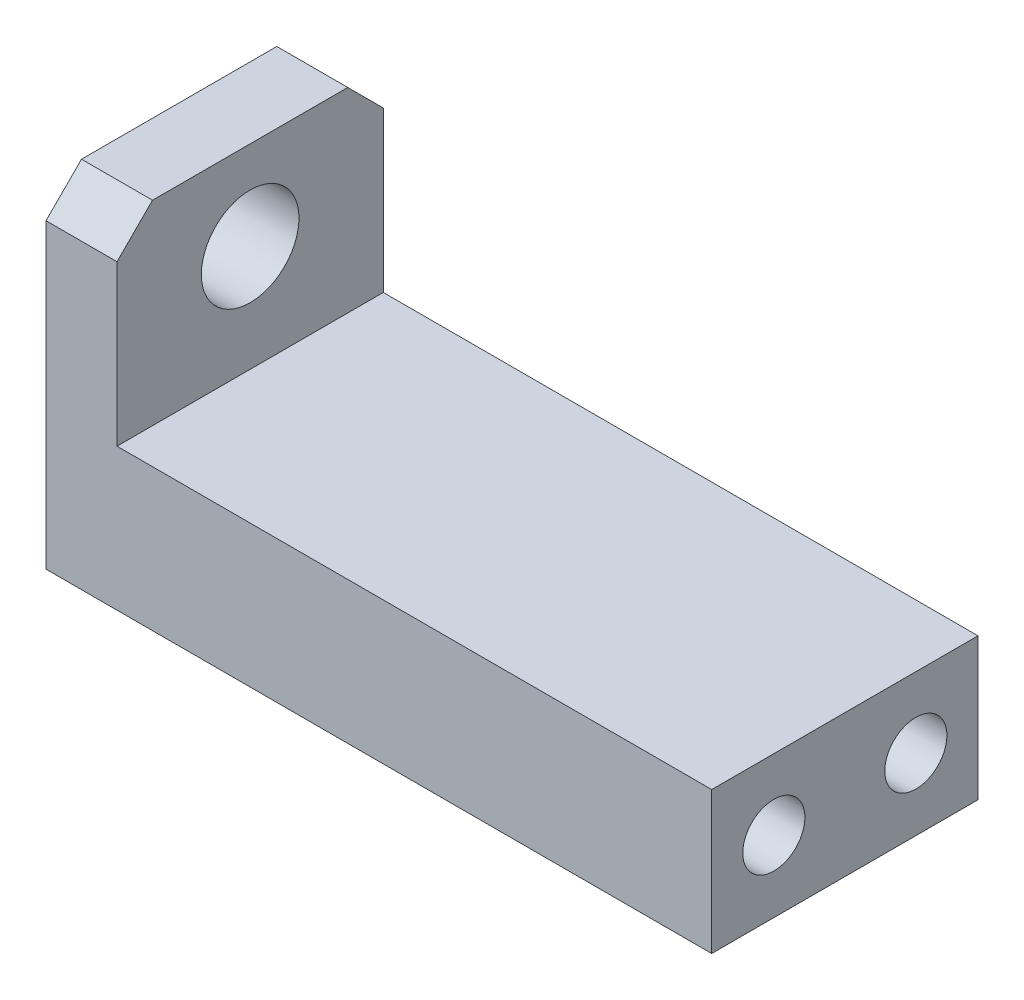
from build123d import *

# Parameters (mm, degrees)
BOSS_EXTRUDE1_DEPTH = 15
SKETCH2_R           = 2.75
SKETCH2_R_2         = 3
SKETCH2_R_3         = 1.75
CUT_EXTRUDE1_DEPTH  = 15
SKETCH3_R           = 1.75
CUT_EXTRUDE2_DEPTH  = 38.5
CHAMFER1_SIZE       = 2


with BuildPart() as part:
    # Sketch1 → Boss-Extrude1 (new body)
    with BuildSketch(Plane.XY):
        Polygon((-12.163709917, 2.060150376), (-8.163709917, 2.060150376), (-8.163709917, -8.939849624), (25.336290083, -8.939849624), (25.336290083, -16.939849624), (-12.163709917, -16.939849624), align=None)
    extrude(amount=BOSS_EXTRUDE1_DEPTH)

    # Sketch2 → Cut-Extrude1 (cut)
    with BuildSketch(Plane.ZY.offset(12.163709917)):
        with Locations((7.5, -2.939849624)):
            Circle(SKETCH2_R)
        with Locations((11.5, -12.914706032)):
            Circle(SKETCH2_R_2)
        with Locations((11.5, -12.914706032)):
            Circle(SKETCH2_R_3, mode=Mode.SUBTRACT)
        with Locations((3.5, -12.914706032)):
            Circle(SKETCH2_R_2)
        with Locations((3.5, -12.914706032)):
            Circle(SKETCH2_R_3, mode=Mode.SUBTRACT)
    extrude(amount=-CUT_EXTRUDE1_DEPTH, mode=Mode.SUBTRACT)

    # Sketch3 → Cut-Extrude2 (cut, through all)
    with BuildSketch(Plane.ZY.offset(12.163709917)):
        with Locations((3.5, -12.914706032)):
            Circle(SKETCH3_R)
        with Locations((11.5, -12.914706032)):
            Circle(SKETCH3_R)
    extrude(amount=-CUT_EXTRUDE2_DEPTH, mode=Mode.SUBTRACT)

    # Chamfer1
    chamfer1_edges = [part.edges().sort_by_distance(p)[0] for p in [
        (-10.163709917, 2.060150376, 15),
        (-10.163709917, 2.060150376, 0),
    ]]
    chamfer(chamfer1_edges, length=CHAMFER1_SIZE)


solid = part.part
